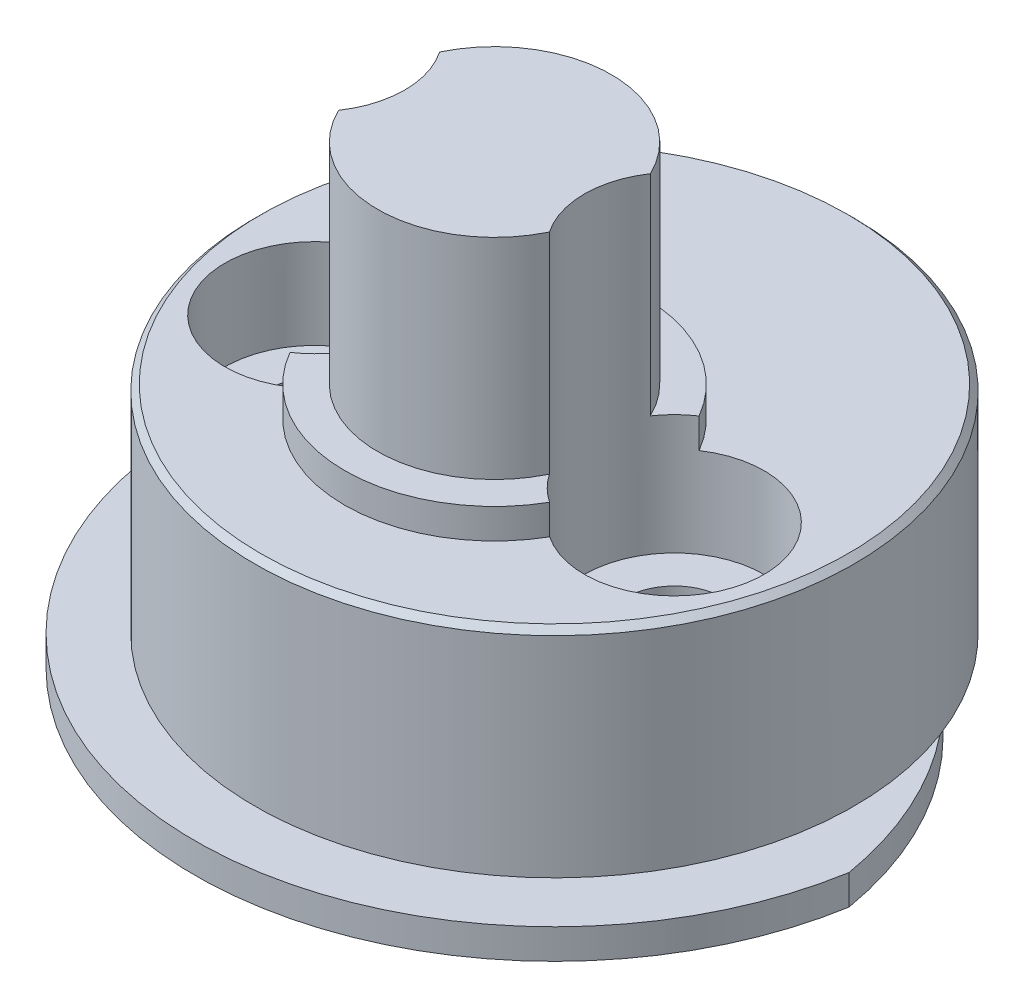
from build123d import *

# Parameters (mm, degrees)
SKETCH1_R               = 1.65
SKETCH1_W               = 5.5
SKETCH1_H               = 10.5
BOSS_EXTRUDE1_DEPTH     = 1
SKETCH2_R               = 10
SKETCH2_R_2             = 1.65
SKETCH2_W               = 5.5
SKETCH2_H               = 10.5
BOSS_EXTRUDE2_DEPTH     = 4.2
SKETCH3_R               = 10
SKETCH3_R_2             = 1.65
BOSS_EXTRUDE3_DEPTH     = 3
SKETCH4_R               = 5
BOSS_EXTRUDE4_DEPTH     = 1
SKETCH5_R               = 3.9
BOSS_EXTRUDE5_DEPTH     = 7
SKETCH6_R               = 3
CUT_EXTRUDE1_DEPTH      = 10
CUT_EXTRUDE1_DEPTH_BACK = 4
CHAMFER1_SIZE           = 0.2


with BuildPart() as part:
    # Sketch1 → Boss-Extrude1 (new body)
    with BuildSketch(Plane(origin=(0, 0, 0), x_dir=(1, 0, 0), z_dir=(0, 1, 0))):
        with BuildLine():
            ThreePointArc((-11.832159566, 0), (0, -10), (11.832159566, 0))
            ThreePointArc((11.832159566, 0), (0, 10), (-11.832159566, 0))
        make_face()
        with Locations(Location((-6, 0, 0), (0, 0, 270))):
            Circle(SKETCH1_R, mode=Mode.SUBTRACT)
        with Locations(Location((6, 0, 0), (0, 0, 270))):
            Circle(SKETCH1_R, mode=Mode.SUBTRACT)
        Rectangle(SKETCH1_W, SKETCH1_H, mode=Mode.SUBTRACT)
    extrude(amount=BOSS_EXTRUDE1_DEPTH)

    # Sketch2 → Boss-Extrude2 (add)
    with BuildSketch(Plane(origin=(0, 1, 0), x_dir=(1, 0, 0), z_dir=(0, 1, 0))):
        with Locations(Location((0, 2, 0), (0, 0, 159.512684885))):
            Circle(SKETCH2_R)
        with Locations(Location((6, 0, 0), (0, 0, 270))):
            Circle(SKETCH2_R_2, mode=Mode.SUBTRACT)
        with Locations(Location((-6, 0, 0), (0, 0, 270))):
            Circle(SKETCH2_R_2, mode=Mode.SUBTRACT)
        Rectangle(SKETCH2_W, SKETCH2_H, mode=Mode.SUBTRACT)
    extrude(amount=BOSS_EXTRUDE2_DEPTH)

    # Sketch3 → Boss-Extrude3 (add)
    with BuildSketch(Plane(origin=(0, 5.2, 0), x_dir=(1, 0, 0), z_dir=(0, 1, 0))):
        with Locations(Location((0, 2, 0), (0, 0, 159.512684885))):
            Circle(SKETCH3_R)
        with Locations(Location((6, 0, 0), (0, 0, 270))):
            Circle(SKETCH3_R_2, mode=Mode.SUBTRACT)
        with Locations(Location((-6, 0, 0), (0, 0, 270))):
            Circle(SKETCH3_R_2, mode=Mode.SUBTRACT)
    extrude(amount=BOSS_EXTRUDE3_DEPTH)

    # Sketch4 → Boss-Extrude4 (add)
    with BuildSketch(Plane(origin=(0, 8.2, 0), x_dir=(1, 0, 0), z_dir=(0, 1, 0))):
        with Locations(Location((0, 0, 0), (0, 0, 13.762144757))):
            Circle(SKETCH4_R)
    extrude(amount=BOSS_EXTRUDE4_DEPTH)

    # Sketch5 → Boss-Extrude5 (add)
    with BuildSketch(Plane(origin=(0, 9.2, 0), x_dir=(1, 0, 0), z_dir=(0, 1, 0))):
        with Locations(Location((0, 0, 0), (0, 0, 270))):
            Circle(SKETCH5_R)
    extrude(amount=BOSS_EXTRUDE5_DEPTH)

    # Sketch6 → Cut-Extrude1 (cut, two sides)
    with BuildSketch(Plane(origin=(0, 9.2, 0), x_dir=(1, 0, 0), z_dir=(0, 1, 0))) as cut_extrude1_sk:
        with Locations(Location((-6, 0, 0), (0, 0, 56.251011404))):
            Circle(SKETCH6_R)
        with Locations(Location((6, 0, 0), (0, 0, 123.748988596))):
            Circle(SKETCH6_R)
    extrude(amount=CUT_EXTRUDE1_DEPTH, mode=Mode.SUBTRACT)
    extrude(cut_extrude1_sk.sketch, amount=-CUT_EXTRUDE1_DEPTH_BACK, mode=Mode.SUBTRACT)

    # Chamfer1
    chamfer1_edges = [part.edges().sort_by_distance(p)[0] for p in [
        (9.367496998, 8.2, 1.5),
    ]]
    chamfer(chamfer1_edges, length=CHAMFER1_SIZE)


solid = part.part
